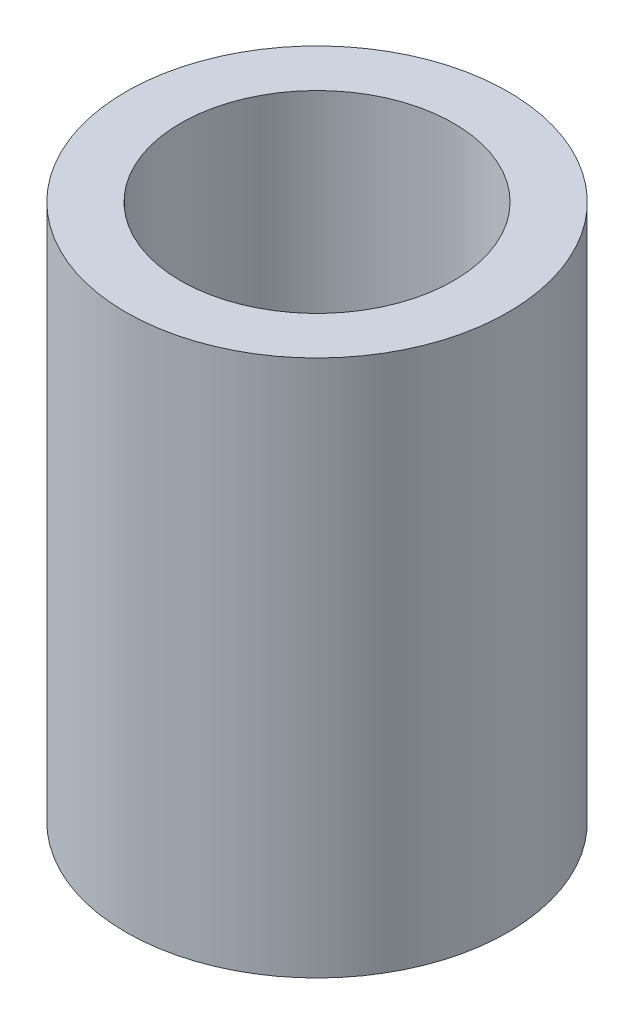
from build123d import *

# Parameters (mm, degrees)
SKETCH1_R           = 2.1
SKETCH1_R_2         = 1.5
BOSS_EXTRUDE1_DEPTH = 5.9


with BuildPart() as part:
    # Sketch1 → Boss-Extrude1 (new body)
    with BuildSketch(Plane(origin=(0, 0, 0), x_dir=(1, 0, 0), z_dir=(0, 1, 0))):
        Circle(SKETCH1_R)
        Circle(SKETCH1_R_2, mode=Mode.SUBTRACT)
    extrude(amount=BOSS_EXTRUDE1_DEPTH)


solid = part.part
